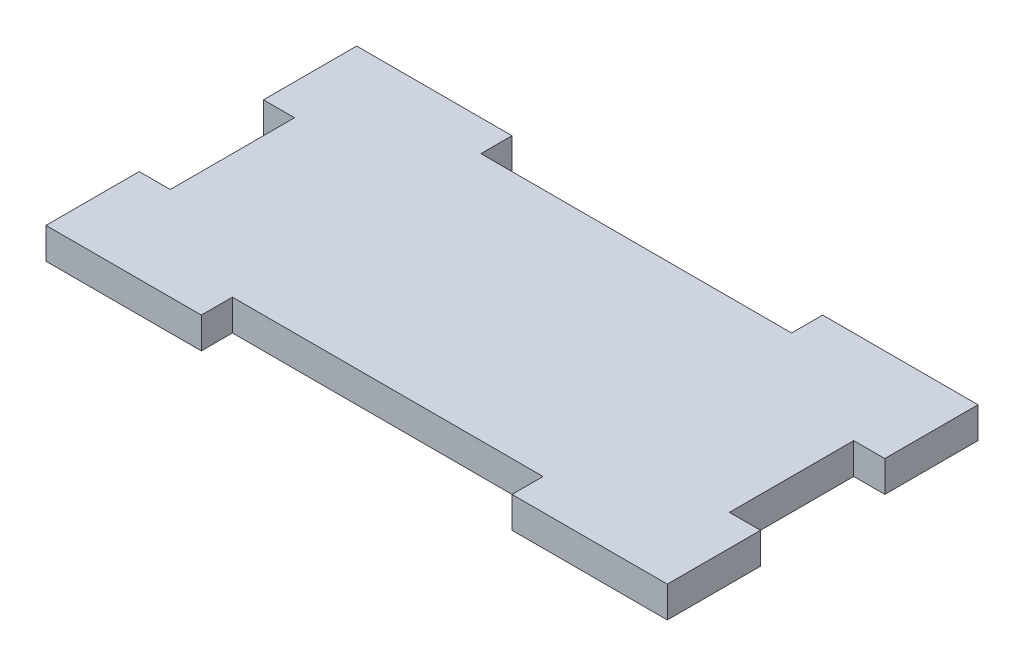
from build123d import *

# Parameters (mm, degrees)
BOSS_EXTRUDE1_DEPTH = 5


with BuildPart() as part:
    # Sketch1 → Boss-Extrude1 (new body)
    with BuildSketch(Plane(origin=(0, 0, 0), x_dir=(1, 0, 0), z_dir=(0, 1, 0))):
        Polygon((-50, -9.015246381), (-50, -24.015246381), (-25, -24.015246381), (-25, -19.015246381), (25, -19.015246381), (25, -24.015246381), (50, -24.015246381), (50, -9.015246381), (45, -9.015246381), (45, 10.984753619), (50, 10.984753619), (50, 25.984753619), (25, 25.984753619), (25, 20.984753619), (-25, 20.984753619), (-25, 25.984753619), (-50, 25.984753619), (-50, 10.984753619), (-45, 10.984753619), (-45, -9.015246381), align=None)
    extrude(amount=BOSS_EXTRUDE1_DEPTH)


solid = part.part
